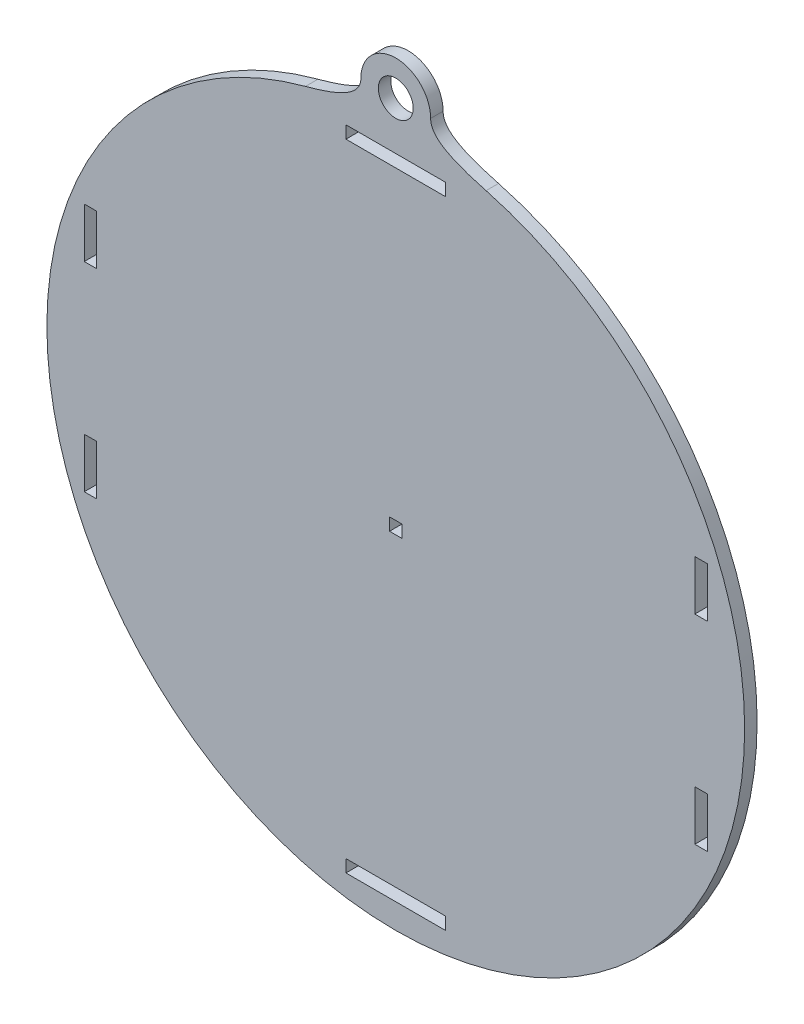
from build123d import *

# Parameters (mm, degrees)
SKETCH1_R           = 4.445
SKETCH1_W           = 3.175
SKETCH1_H           = 12.7
SKETCH1_H_2         = 3.175
SKETCH1_W_2         = 25.4
BOSS_EXTRUDE1_DEPTH = 3.175


with BuildPart() as part:
    # Sketch1 → Boss-Extrude1 (new body)
    with BuildSketch(Plane.XY):
        with BuildLine():
            ThreePointArc((-23.00901311, 85.870805957), (0, -88.9), (23.00901311, 85.870805957))
            add(Edge.make_bspline(
                [(23.00901311, 85.870805957), (14.830841114, 88.062140539), (8.89, 90.527472624), (8.89, 94.760805957)],
                knots=[0, 0, 0, 0, 1, 1, 1, 1], degree=3))
            ThreePointArc((8.89, 94.760805957), (0, 103.650805957), (-8.89, 94.760805957))
            add(Edge.make_bspline(
                [(-23.00901311, 85.870805957), (-14.830841114, 88.062140539), (-8.89, 90.527472624), (-8.89, 94.760805957)],
                knots=[0, 0, 0, 0, 1, 1, 1, 1], degree=3))
        make_face()
        with Locations((0, 94.760805957)):
            Circle(SKETCH1_R, mode=Mode.SUBTRACT)
        with Locations((77.7875, 25.38476)):
            Rectangle(SKETCH1_W, SKETCH1_H, mode=Mode.SUBTRACT)
        Rectangle(SKETCH1_W, SKETCH1_H_2, mode=Mode.SUBTRACT)
        with Locations((77.7875, -25.41524)):
            Rectangle(SKETCH1_W, SKETCH1_H, mode=Mode.SUBTRACT)
        with Locations((-77.7875, -25.41524)):
            Rectangle(SKETCH1_W, SKETCH1_H, mode=Mode.SUBTRACT)
        with Locations((-77.7875, 25.38476)):
            Rectangle(SKETCH1_W, SKETCH1_H, mode=Mode.SUBTRACT)
        with Locations((0, 80.9625)):
            Rectangle(SKETCH1_W_2, SKETCH1_H_2, mode=Mode.SUBTRACT)
        with Locations((0, -80.9625)):
            Rectangle(SKETCH1_W_2, SKETCH1_H_2, mode=Mode.SUBTRACT)
    extrude(amount=BOSS_EXTRUDE1_DEPTH)


solid = part.part
